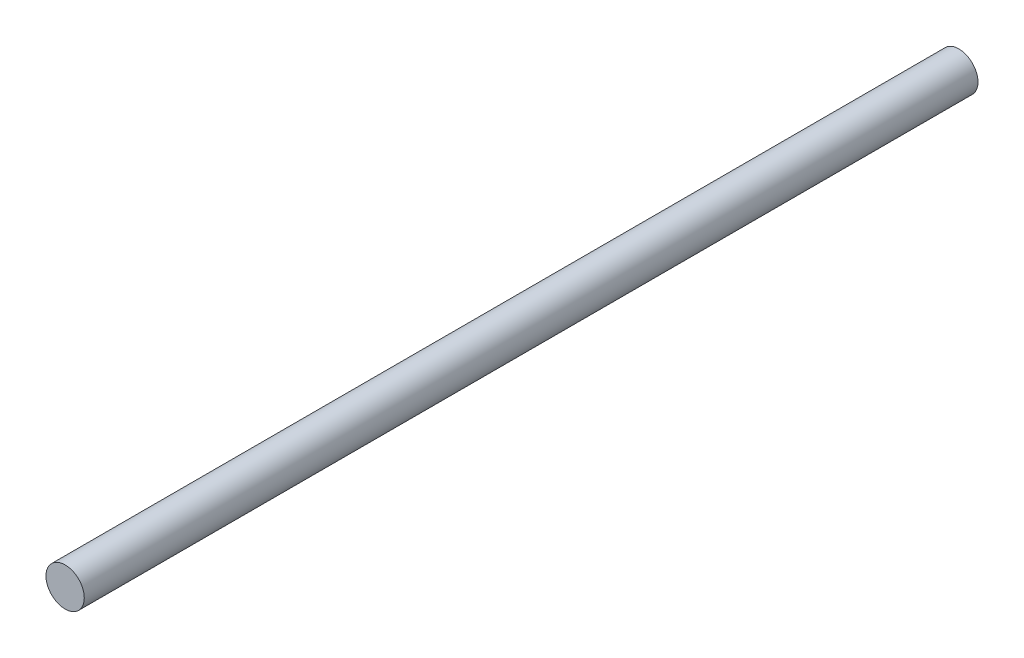
from build123d import *

# Parameters (mm, degrees)
SKETCH_1_R      = 3
EXTRUDE_1_DEPTH = 140


with BuildPart() as part:
    # ｽｹｯﾁ1 → ﾎﾞｽ - 押し出し1 (new body)
    with BuildSketch(Plane.XY):
        Circle(SKETCH_1_R)
    extrude(amount=EXTRUDE_1_DEPTH)


solid = part.part
